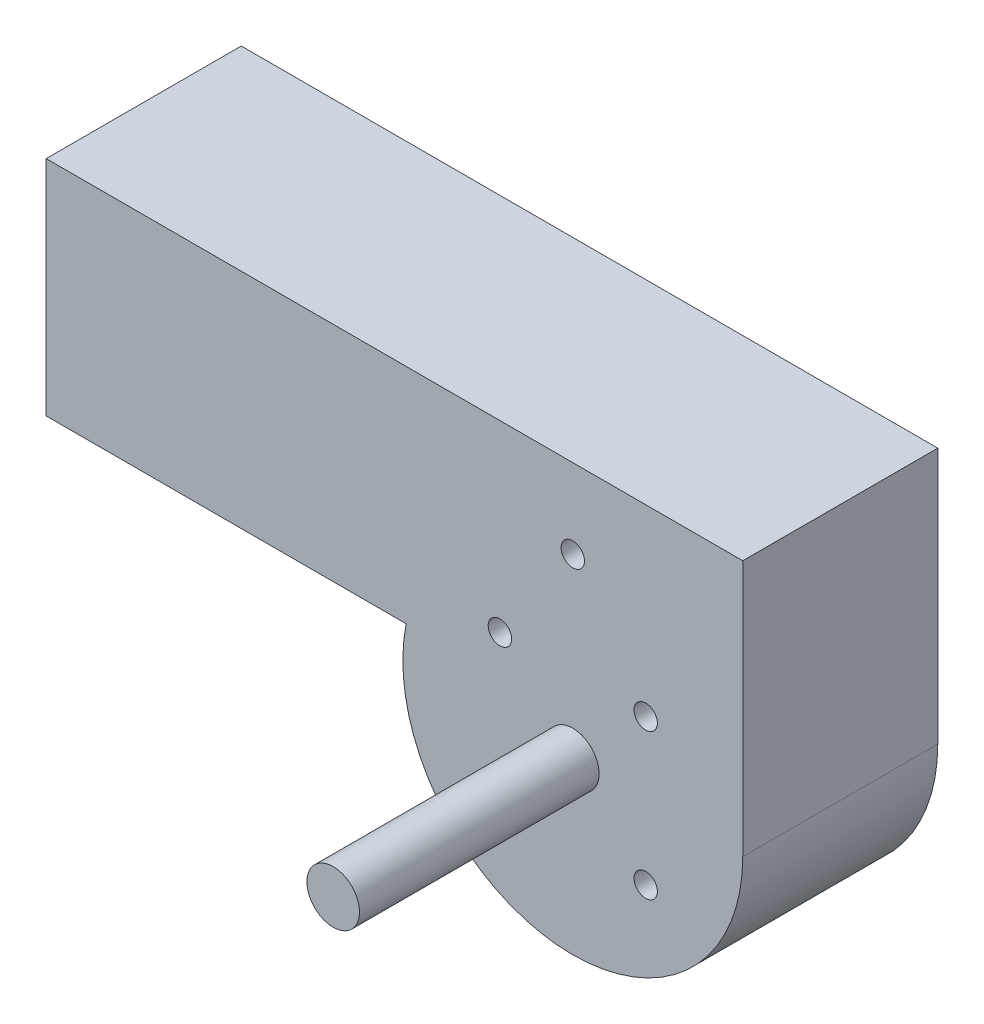
from build123d import *

# Parameters (mm, degrees)
SKETCH1_R           = 4.2
BOSS_EXTRUDE1_DEPTH = 70
SKETCH2_R           = 9.44
BOSS_EXTRUDE2_DEPTH = 86


with BuildPart() as part:
    # Sketch1 → Boss-Extrude1 (new body)
    with BuildSketch(Plane.XY):
        with BuildLine():
            Line((61, 0), (61, 92))
            Line((61, 92), (-189, 92))
            Line((-189, 92), (-189, 12))
            Line((-189, 12), (-59.808026217, 12))
            ThreePointArc((-59.808026217, 12), (-6.029527376, -60.701275107), (61, 0))
        make_face()
        with Locations((26.162950904, 26.162950904)):
            Circle(SKETCH1_R, mode=Mode.SUBTRACT)
        with Locations((26.162950904, -26.162950904)):
            Circle(SKETCH1_R, mode=Mode.SUBTRACT)
        with Locations((-26.162950904, -26.162950904)):
            Circle(SKETCH1_R, mode=Mode.SUBTRACT)
        with Locations((-26.162950904, 26.162950904)):
            Circle(SKETCH1_R, mode=Mode.SUBTRACT)
        with Locations((0, 63.5)):
            Circle(SKETCH1_R, mode=Mode.SUBTRACT)
    extrude(amount=-BOSS_EXTRUDE1_DEPTH)

    # Sketch2 → Boss-Extrude2 (add)
    with BuildSketch(Plane.XY):
        Circle(SKETCH2_R)
    extrude(amount=BOSS_EXTRUDE2_DEPTH)


solid = part.part
